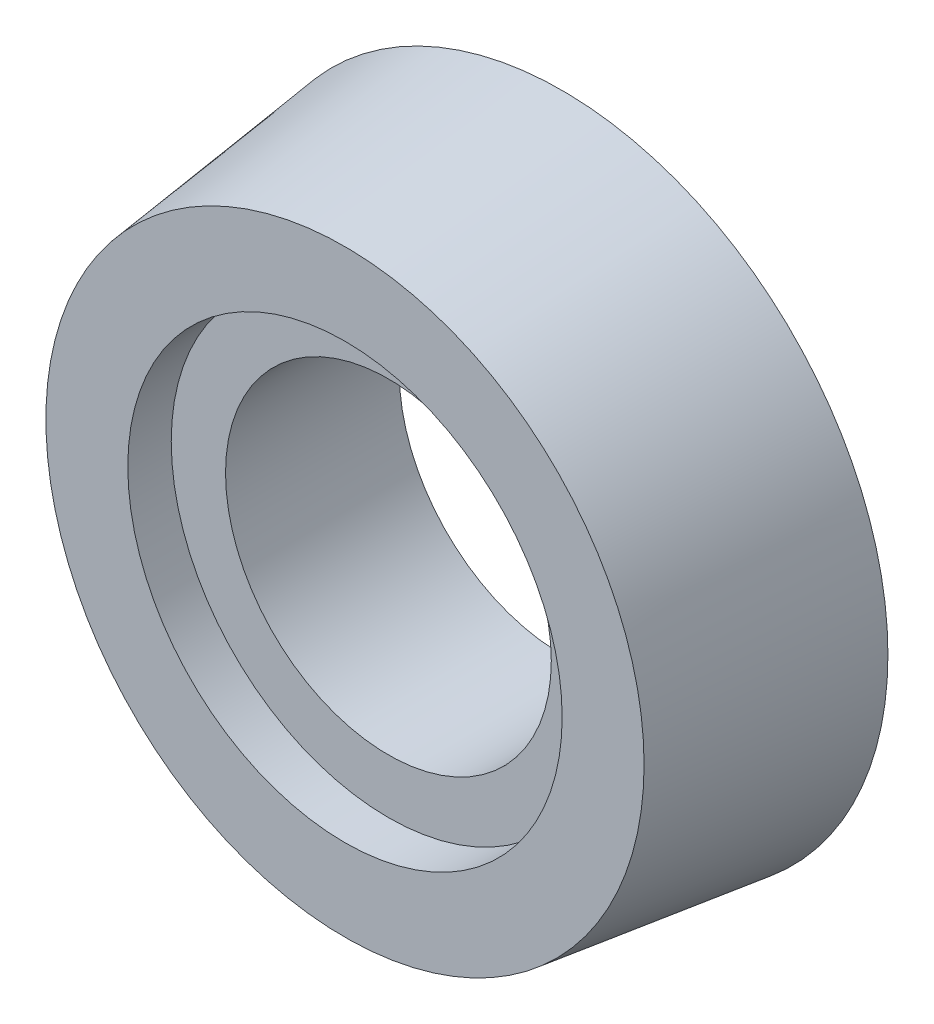
from build123d import *

# Parameters (mm, degrees)
SKETCH1_R           = 30
BOSS_EXTRUDE1_DEPTH = 20
BOSS_EXTRUDE1_TAPER = 7
SKETCH3_R           = 15
CUT_EXTRUDE1_DEPTH  = 21
SKETCH5_R           = 20
CUT_EXTRUDE2_DEPTH  = 4


with BuildPart() as part:
    # Sketch1 → Boss-Extrude1 (new body)
    with BuildSketch(Plane.XY):
        Circle(SKETCH1_R)
    extrude(amount=BOSS_EXTRUDE1_DEPTH, taper=BOSS_EXTRUDE1_TAPER)

    # Sketch3 → Cut-Extrude1 (cut, through all)
    with BuildSketch(Plane(origin=(0, 0, 0), x_dir=(-1, 0, 0), z_dir=(0, 0, -1))):
        Circle(SKETCH3_R)
    extrude(amount=-CUT_EXTRUDE1_DEPTH, mode=Mode.SUBTRACT)

    # Sketch5 → Cut-Extrude2 (cut)
    with BuildSketch(Plane.XY.offset(20)):
        Circle(SKETCH5_R)
    extrude(amount=-CUT_EXTRUDE2_DEPTH, mode=Mode.SUBTRACT)


solid = part.part
